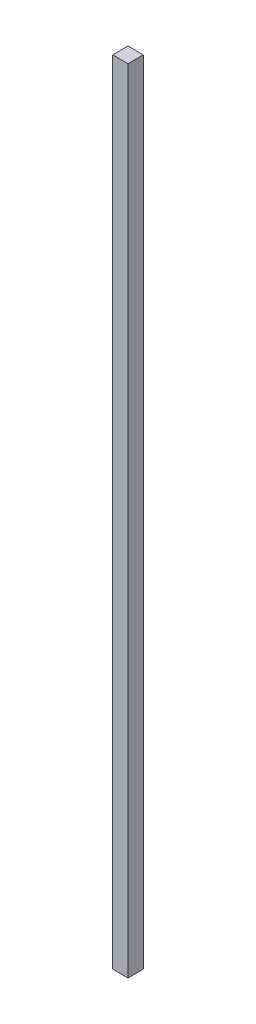
from build123d import *

# Parameters (mm, degrees)
ESQUISSE1_W        = 10
ESQUISSE1_H        = 517
BOSS_EXTRU_1_DEPTH = 10


with BuildPart() as part:
    # Esquisse1 → Boss.-Extru.1 (new body)
    with BuildSketch(Plane.XY):
        with Locations((-15.484022556, -237.281512605)):
            Rectangle(ESQUISSE1_W, ESQUISSE1_H)
    extrude(amount=BOSS_EXTRU_1_DEPTH)


solid = part.part
